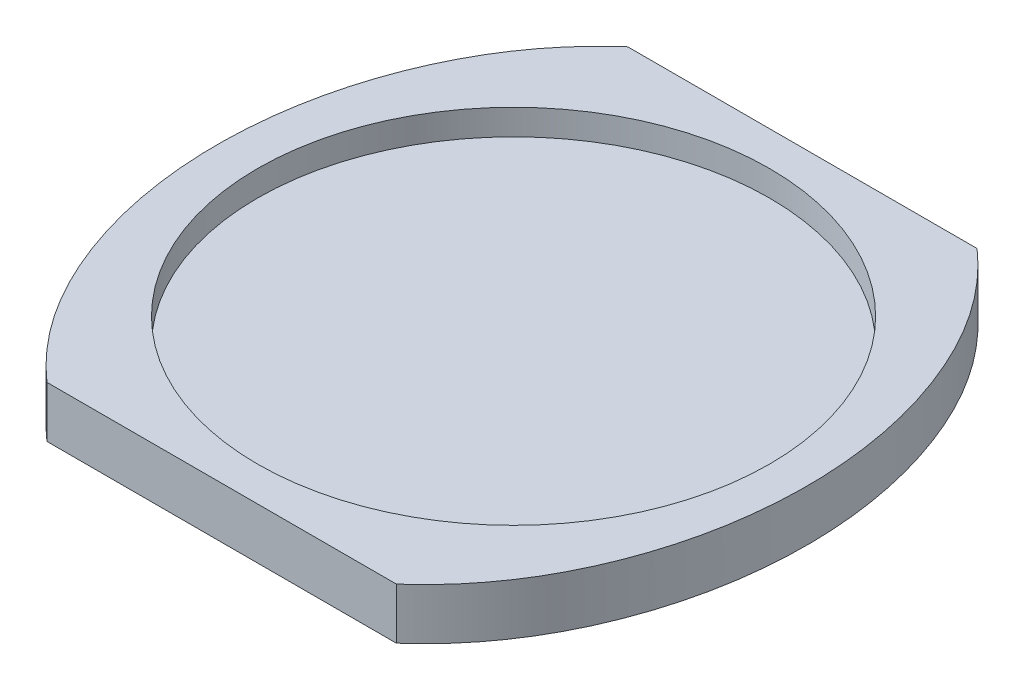
from build123d import *

# Parameters (mm, degrees)
BOSS_EXTRUDE1_DEPTH     = 10
SKETCH1_3_R             = 100
BOSS_EXTRUDE2_DEPTH     = 10
SKETCH2_W               = 214.561996695
SKETCH2_H               = 67.979229187
CUT_EXTRUDE1_DEPTH      = 1.0000001
CUT_EXTRUDE1_DEPTH_BACK = 21.0000001


with BuildPart() as part:
    # Sketch1 → Boss-Extrude1 (new body, symmetric)
    with BuildSketch(Plane(origin=(0, 0, 0), x_dir=(1, 0, 0), z_dir=(0, 1, 0))):
        with BuildLine():
            add(Edge.make_bspline(
                [(0.976121303, -140.025549951), (2.374162629, -140.009491535), (3.771517421, -139.962591197), (7.291103261, -139.767278285), (9.398709168, -139.579437143), (15.675293836, -138.811953228), (19.799111475, -138.029795642), (27.929813311, -135.94328184), (31.936744561, -134.639135756), (37.859712235, -132.29247735), (39.804221595, -131.450894746), (43.623558737, -129.659192276), (45.500465995, -128.708195239), (51.0358335, -125.694698111), (54.599581786, -123.47277318), (59.764651016, -119.835967833), (61.45615035, -118.57288108), (63.948397978, -116.602501944), (64.77264308, -115.932207196), (66.398329816, -114.572915867), (67.200371286, -113.883479536), (71.15781434, -110.388473165), (74.15557851, -107.440023102), (79.839048175, -101.260277994), (82.526531921, -98.030594728), (86.325197715, -92.975281331), (87.552083684, -91.254523379), (89.92827313, -87.74268795), (91.071161278, -85.961213119), (93.264204581, -82.358005966), (94.315491716, -80.534886626), (96.329914932, -76.846718964), (97.291887312, -74.981117129), (100.057054093, -69.326876807), (101.744965365, -65.483403988), (104.050207299, -59.610400761), (104.780795243, -57.634741095), (106.166809965, -53.647671411), (106.823248507, -51.632689638), (108.669969422, -45.566700204), (109.738950442, -41.49400287), (111.566738836, -33.293705648), (112.32543315, -29.166085749), (113.538180225, -20.85692261), (113.992347502, -16.67539964), (114.36903765, -11.414684455), (114.434803631, -10.360847109), (114.547109075, -8.249769211), (114.593657534, -7.191844363), (114.703986475, -4.02388278), (114.738672, -1.916622031), (114.721208012, 8.596531177), (114.100106338, 16.933423498), (112.26337389, 29.32899767), (111.499343946, 33.442447781), (110.118494221, 39.584146802), (109.369324409, 42.647871971), (108.529677635, 45.700624473), (107.949499474, 47.733317125), (107.648881576, 48.749432437), (106.100547872, 53.802562864), (104.714467284, 57.768944772), (101.648347062, 65.549912048), (99.96820604, 69.364445062), (97.222621896, 74.969865164), (96.268251936, 76.818108957), (94.2727099, 80.469773084), (93.232568116, 82.273725448), (89.982350098, 87.618559335), (87.642859175, 91.092612835), (84.48192294, 95.313016777), (83.837654689, 96.150859096), (82.525451012, 97.814322319), (81.856640259, 98.64121338), (79.822125033, 101.093717437), (78.430527447, 102.688859664), (74.149311898, 107.353958125), (71.153616848, 110.303977016), (64.867354765, 115.870614214), (61.576656322, 118.487083942), (56.404777152, 122.145142784), (54.641398693, 123.31992646), (51.934089957, 125.011728379), (51.023681699, 125.562366877), (49.193658371, 126.632857883), (48.273010775, 127.153359084), (43.641538937, 129.682001779), (39.846190182, 131.469016566), (32.072993706, 134.565606006), (28.09510057, 135.875061848), (21.983291629, 137.459987939), (19.921721798, 137.924724312), (16.791518565, 138.522812496), (15.740120954, 138.705899718), (13.634978124, 139.036596855), (12.581020534, 139.184317529), (8.013946499, 139.747161721), (4.486924522, 139.985449555), (0.944318009, 140.025549951)],
                knots=[0.005345243, 0.005345243, 0.005345243, 0.005345243, 0.015625, 0.015625, 0.03125, 0.03125, 0.0625, 0.0625, 0.09375, 0.09375, 0.109375, 0.109375, 0.125, 0.125, 0.15625, 0.15625, 0.171875, 0.171875, 0.1796875, 0.1796875, 0.1875, 0.1875, 0.21875, 0.21875, 0.25, 0.25, 0.265625, 0.265625, 0.28125, 0.28125, 0.296875, 0.296875, 0.3125, 0.3125, 0.34375, 0.34375, 0.359375, 0.359375, 0.375, 0.375, 0.40625, 0.40625, 0.4375, 0.4375, 0.46875, 0.46875, 0.4765625, 0.4765625, 0.484375, 0.484375, 0.5, 0.5, 0.5625, 0.5625, 0.59375, 0.59375, 0.609375, 0.6171875, 0.6171875, 0.625, 0.625, 0.65625, 0.65625, 0.6875, 0.6875, 0.703125, 0.703125, 0.71875, 0.71875, 0.75, 0.75, 0.7578125, 0.7578125, 0.765625, 0.765625, 0.78125, 0.78125, 0.8125, 0.8125, 0.84375, 0.84375, 0.859375, 0.859375, 0.8671875, 0.8671875, 0.875, 0.875, 0.90625, 0.90625, 0.9375, 0.9375, 0.953125, 0.953125, 0.9609375, 0.9609375, 0.96875, 0.96875, 0.994746559, 0.994746559, 0.994746559, 0.994746559], degree=3))
            Line((0.944318009, 140.025549951), (0, 140.025549951))
            Line((0, 140.025549951), (0, 100))
            ThreePointArc((0, 100), (70.710678119, 70.710678119), (100, 0))
            ThreePointArc((100, 0), (70.710678119, -70.710678119), (0, -100))
            Line((0, -100), (0, -140.025549951))
            Line((0, -140.025549951), (0.976121303, -140.025549951))
        make_face()
        with BuildLine():
            Line((0, 100), (0, 140.025549951))
            add(Edge.make_bspline(
                [(0, 140.025549951), (-0.197417557, 140.027819409), (-0.394821383, 140.02947205), (-0.592211495, 140.030508539)],
                knots=[0, 0, 0, 0, 0.001450863, 0.001450863, 0.001450863, 0.001450863], degree=3))
            add(Edge.make_bspline(
                [(-0.592211495, 140.030508539), (-2.520604536, 140.040634466), (-4.447688548, 139.99195347), (-8.496389648, 139.767278285), (-10.603995555, 139.579437143), (-16.880580223, 138.811953228), (-21.004397862, 138.029795642), (-29.135099698, 135.94328184), (-33.142030948, 134.639135756), (-39.064998622, 132.29247735), (-41.009507982, 131.450894746), (-44.828845124, 129.659192276), (-46.705752383, 128.708195239), (-52.241119887, 125.694698111), (-55.804868173, 123.47277318), (-60.969937403, 119.835967833), (-62.661436737, 118.57288108), (-65.153684365, 116.602501944), (-65.977929468, 115.932207196), (-67.603616203, 114.572915867), (-68.405657673, 113.883479536), (-72.363100727, 110.388473165), (-75.360864897, 107.440023102), (-81.044334562, 101.260277994), (-83.731818308, 98.030594728), (-87.530484102, 92.975281331), (-88.757370071, 91.254523379), (-91.133559517, 87.74268795), (-92.276447665, 85.961213119), (-94.469490968, 82.358005966), (-95.520778103, 80.534886626), (-97.535201319, 76.846718964), (-98.497173699, 74.981117129), (-101.26234048, 69.326876807), (-102.950251753, 65.483403988), (-105.255493686, 59.610400761), (-105.98608163, 57.634741095), (-107.372096352, 53.647671411), (-108.028534894, 51.632689638), (-109.875255809, 45.566700204), (-110.944236829, 41.49400287), (-112.772025223, 33.293705648), (-113.530719537, 29.166085749), (-114.743466612, 20.85692261), (-115.197633889, 16.67539964), (-115.574324037, 11.414684455), (-115.640090018, 10.360847109), (-115.752395462, 8.249769211), (-115.798943921, 7.191844363), (-115.909272862, 4.02388278), (-115.943958388, 1.916622031), (-115.926494399, -8.596531177), (-115.305392725, -16.933423498), (-113.468660278, -29.32899767), (-112.704630333, -33.442447781), (-111.323780608, -39.584146802), (-110.574610796, -42.647871971), (-109.734964023, -45.700624473), (-109.154785861, -47.733317125), (-108.854167963, -48.749432437), (-107.305834259, -53.802562864), (-105.919753671, -57.768944772), (-102.85363345, -65.549912048), (-101.173492427, -69.364445062), (-98.427908283, -74.969865164), (-97.473538324, -76.818108957), (-95.477996287, -80.469773084), (-94.437854503, -82.273725448), (-91.187636485, -87.618559335), (-88.848145562, -91.092612835), (-85.687209327, -95.313016777), (-85.042941076, -96.150859096), (-83.730737399, -97.814322319), (-83.061926646, -98.64121338), (-81.02741142, -101.093717437), (-79.635813834, -102.688859664), (-75.354598285, -107.353958125), (-72.358903236, -110.303977016), (-66.072641152, -115.870614214), (-62.781942709, -118.487083942), (-57.610063539, -122.145142784), (-55.84668508, -123.31992646), (-53.139376344, -125.011728379), (-52.228968086, -125.562366877), (-50.398944758, -126.632857883), (-49.478297162, -127.153359084), (-44.846825324, -129.682001779), (-41.051476569, -131.469016566), (-33.278280093, -134.565606006), (-29.300386957, -135.875061848), (-23.188578016, -137.459987939), (-21.127008185, -137.924724312), (-17.996804952, -138.522812496), (-16.945407341, -138.705899718), (-14.840264511, -139.036596855), (-13.786306921, -139.184317529), (-8.711843514, -139.809692163), (-4.672693328, -140.050246998), (-0.613074893, -140.030508539)],
                knots=[0.001450863, 0.001450863, 0.001450863, 0.001450863, 0.015625, 0.015625, 0.03125, 0.03125, 0.0625, 0.0625, 0.09375, 0.09375, 0.109375, 0.109375, 0.125, 0.125, 0.15625, 0.15625, 0.171875, 0.171875, 0.1796875, 0.1796875, 0.1875, 0.1875, 0.21875, 0.21875, 0.25, 0.25, 0.265625, 0.265625, 0.28125, 0.28125, 0.296875, 0.296875, 0.3125, 0.3125, 0.34375, 0.34375, 0.359375, 0.359375, 0.375, 0.375, 0.40625, 0.40625, 0.4375, 0.4375, 0.46875, 0.46875, 0.4765625, 0.4765625, 0.484375, 0.484375, 0.5, 0.5, 0.5625, 0.5625, 0.59375, 0.59375, 0.609375, 0.6171875, 0.6171875, 0.625, 0.625, 0.65625, 0.65625, 0.6875, 0.6875, 0.703125, 0.703125, 0.71875, 0.71875, 0.75, 0.75, 0.7578125, 0.7578125, 0.765625, 0.765625, 0.78125, 0.78125, 0.8125, 0.8125, 0.84375, 0.84375, 0.859375, 0.859375, 0.8671875, 0.8671875, 0.875, 0.875, 0.90625, 0.90625, 0.9375, 0.9375, 0.953125, 0.953125, 0.9609375, 0.9609375, 0.96875, 0.96875, 0.998502653, 0.998502653, 0.998502653, 0.998502653], degree=3))
            add(Edge.make_bspline(
                [(-0.613074893, -140.030508539), (-0.408768455, -140.029515171), (-0.204410176, -140.027862544), (0, -140.025549951)],
                knots=[0.998502653, 0.998502653, 0.998502653, 0.998502653, 1, 1, 1, 1], degree=3))
            Line((0, -140.025549951), (0, -100))
            ThreePointArc((0, -100), (-100, 0), (0, 100))
        make_face()
    extrude(amount=BOSS_EXTRUDE1_DEPTH, both=True)

    # Sketch1_3 → Boss-Extrude2 (add)
    with BuildSketch(Plane(origin=(0, 0, 0), x_dir=(1, 0, 0), z_dir=(0, 1, 0))):
        Circle(SKETCH1_3_R)
        with BuildLine():
            ThreePointArc((100, 0), (70.710678119, 70.710678119), (0, 100))
            Line((0, 100), (0, -100))
            ThreePointArc((0, -100), (70.710678119, -70.710678119), (100, 0))
        make_face()
        with BuildLine():
            Line((0, -100), (0, 100))
            ThreePointArc((0, 100), (-100, 0), (0, -100))
        make_face()
    extrude(amount=-BOSS_EXTRUDE2_DEPTH)

    # Sketch2 → Cut-Extrude1 (cut, two sides)
    with BuildSketch(Plane(origin=(0, 10, 0), x_dir=(1, 0, 0), z_dir=(0, 1, 0))) as cut_extrude1_sk:
        with Locations((-8.659676613, -147.450639379)):
            Rectangle(SKETCH2_W, SKETCH2_H)
        with Locations((-8.659676613, 147.450639379)):
            Rectangle(SKETCH2_W, SKETCH2_H)
    extrude(amount=CUT_EXTRUDE1_DEPTH, mode=Mode.SUBTRACT)
    extrude(cut_extrude1_sk.sketch, amount=-CUT_EXTRUDE1_DEPTH_BACK, mode=Mode.SUBTRACT)


solid = part.part
